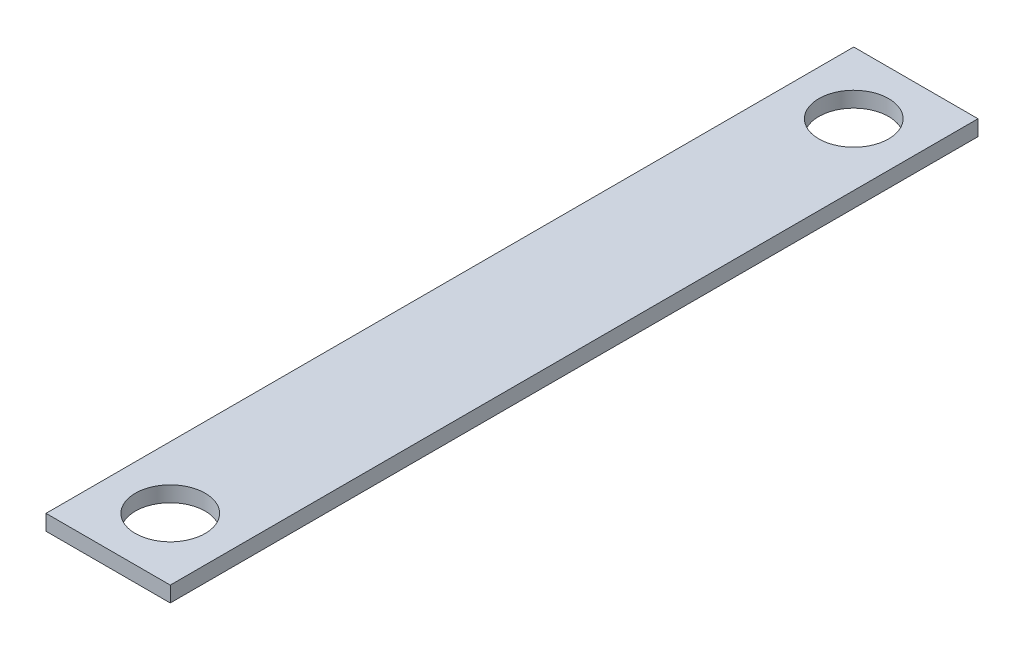
from build123d import *

# Parameters (mm, degrees)
SKETCH1_W           = 50.8
SKETCH1_H           = 330.2
SKETCH1_R           = 14.2748
BOSS_EXTRUDE2_DEPTH = 6.35


with BuildPart() as part:
    # Sketch1 → Boss-Extrude2 (new body)
    with BuildSketch(Plane(origin=(0, 0, 0), x_dir=(1, 0, 0), z_dir=(0, 1, 0))):
        with Locations((25.4, 165.1)):
            Rectangle(SKETCH1_W, SKETCH1_H)
        with Locations((25.4, 25.4)):
            Circle(SKETCH1_R, mode=Mode.SUBTRACT)
        with Locations((25.4, 304.8)):
            Circle(SKETCH1_R, mode=Mode.SUBTRACT)
    extrude(amount=BOSS_EXTRUDE2_DEPTH)


solid = part.part
